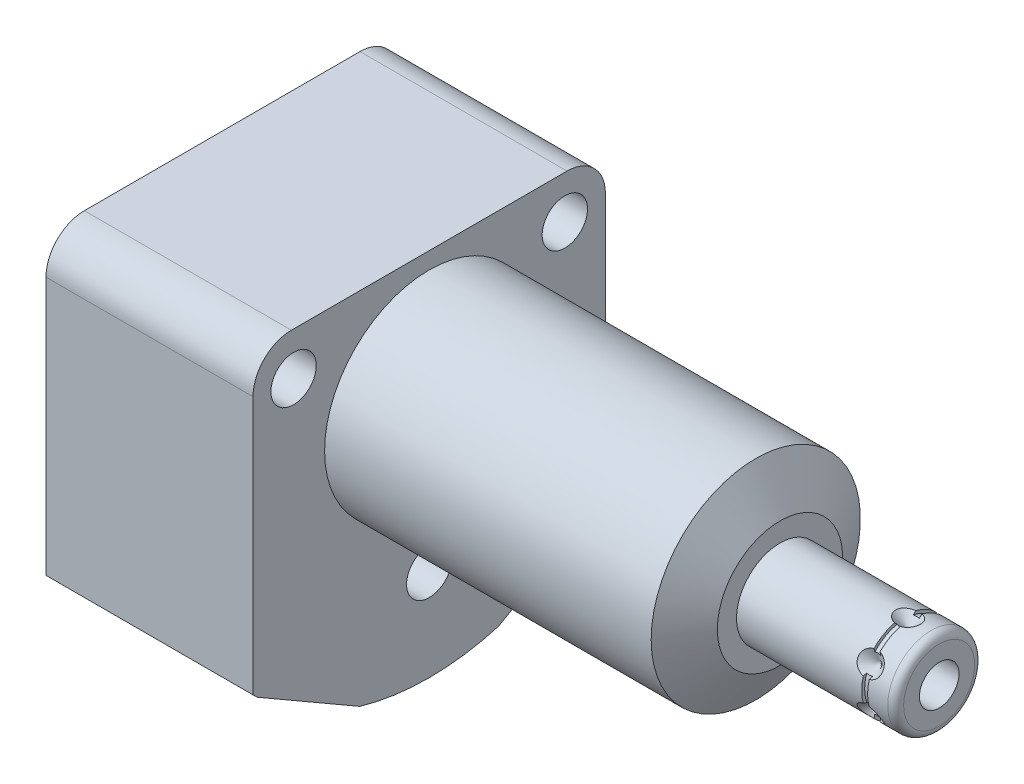
from build123d import *

# Parameters (mm, degrees)
EXTRUDE1_DEPTH           = 44.8056
EXTRUDE1_DEPTH_BACK      = 26.4414
CUT_EXTRUDE1_REACH       = 46.806
SKETCH2_R                = 13.3604
SKETCH11_W               = 0.762
SKETCH11_H               = 0.381
SKETCH15_R               = 2.7432
EXTRUDE3_DEPTH           = 2.9972
CUT_EXTRUDE2_DEPTH       = 2.54
CHAMFER1_SIZE            = 0.381
CHAMFER1_OF_MIRROR2_SIZE = 0.381
SKETCH21_R               = 0.889
FILLET1_R                = 4.9022
SKETCH22_W               = 2.8955
SKETCH22_H               = 26.4414
HOLE1_AT_2_COUNT         = 2
HOLE1_AT_2_PITCH         = 34.639910603
HOLE1_AT_3_COUNT         = 2
HOLE1_AT_3_PITCH         = 34.639910603
CIRPATTERN1_COUNT        = 6


with BuildPart() as part:
    # Sketch1 → Extrude1 (new body, two sides)
    with BuildSketch(Plane(origin=(0, 0, 0), x_dir=(0, 0, -1), z_dir=(1, 0, 0))) as extrude1_sk:
        with BuildLine():
            Line((-22.5044, 15.494), (-22.5044, -22.396751564))
            ThreePointArc((-22.5044, -22.396751564), (-22.237765115, -22.661515896), (-21.968015496, -22.923106141))
            Line((-21.968015496, -22.923106141), (-8.867984504, -30.486412561))
            ThreePointArc((-8.867984504, -30.486412561), (0, -31.75), (8.867984504, -30.486412561))
            Line((8.867984504, -30.486412561), (21.968015496, -22.923106141))
            ThreePointArc((21.968015496, -22.923106141), (22.237765115, -22.661515896), (22.5044, -22.396751564))
            Line((22.5044, -22.396751564), (22.5044, 15.494))
            Line((22.5044, 15.494), (-22.5044, 15.494))
        make_face()
    extrude(amount=EXTRUDE1_DEPTH)
    extrude(extrude1_sk.sketch, amount=-EXTRUDE1_DEPTH_BACK)

    # Sketch2 → Cut-Extrude1 (cut, up to next)
    with BuildSketch(Plane(origin=(0, 0, 0), x_dir=(0, 0, -1), z_dir=(1, 0, 0)), mode=Mode.PRIVATE) as cut_extrude1_sk1:
        with BuildLine():
            Line((22.5044, 15.494), (-22.5044, 15.494))
            Line((-22.5044, 15.494), (-22.5044, -22.396751564))
            ThreePointArc((-22.5044, -22.396751564), (-22.237765115, -22.661515896), (-21.968015496, -22.923106141))
            Line((-21.968015496, -22.923106141), (-8.867984504, -30.486412561))
            ThreePointArc((-8.867984504, -30.486412561), (0, -31.75), (8.867984504, -30.486412561))
            Line((8.867984504, -30.486412561), (21.968015496, -22.923106141))
            ThreePointArc((21.968015496, -22.923106141), (22.237765115, -22.661515896), (22.5044, -22.396751564))
            Line((22.5044, -22.396751564), (22.5044, 15.494))
        make_face()
        Circle(SKETCH2_R, mode=Mode.SUBTRACT)
    cut_extrude1_tool1 = extrude(cut_extrude1_sk1.sketch, amount=CUT_EXTRUDE1_REACH, mode=Mode.PRIVATE) & part.part
    add(cut_extrude1_tool1.solids().sort_by_distance((0, -3.451376, -21.851883))[0], mode=Mode.SUBTRACT)

    # Sketch3 → Cut-Revolve1 (revolve, cut)
    with BuildSketch(Plane.XY, mode=Mode.PRIVATE) as cut_revolve1_sk:
        Polygon((41.711348967, 13.3604), (44.8056, 8.001), (44.8056, 13.3604), align=None)
    revolve(cut_revolve1_sk.sketch.rotate(Axis((23.304450239, 0, 0), (1, 0, 0)), 90), axis=Axis((23.304450239, 0, 0), (1, 0, 0)), mode=Mode.SUBTRACT)  # turned: the seam where the file's is

    # S2D0002 → Cut-Revolve2 (revolve, cut)
    with BuildSketch(Plane(origin=(-24.9936, -18.1864, 10.49), x_dir=(0, 1, 0), z_dir=(0, 0, 1)), mode=Mode.PRIVATE) as cut_revolve2_sk:
        Polygon((3.2512, 0), (5.7023, 0), (5.7023, 1.4478), (0, 1.4478), (0, -11.9888), (1.2446, -11.9888), (1.2446, -2.9972), (3.2512, -2.9972), align=None)
    cut_revolve2 = revolve(cut_revolve2_sk.sketch.rotate(Axis((-1.435104963, -18.1864, 10.49), (-1, 0, 0)), 90), axis=Axis((-1.435104963, -18.1864, 10.49), (-1, 0, 0)), mode=Mode.SUBTRACT)  # turned: the seam where the file's is

    # Sketch6 → Cut-Revolve4 (revolve, cut)
    with BuildSketch(Plane(origin=(-12.9286, 0, 0), x_dir=(0, 0, -1), z_dir=(1, 0, 0)), mode=Mode.PRIVATE) as cut_revolve4_sk:
        Polygon((-19.580423825, -24.008288899), (-22.435709581, -22.359788899), (-22.562709581, -22.579759351), (-15.418, -26.704759351), (-10.0078, -17.334018072), (-13.835285875, -15.124218072), (-18.788285875, -23.703065722), (-19.516923825, -23.898303672), align=None)
    cut_revolve4 = revolve(cut_revolve4_sk.sketch.rotate(Axis((-12.9286, -11.344731937, 6.549884038), (0, 0.866025404, -0.5)), 180), axis=Axis((-12.9286, -11.344731937, 6.549884038), (0, 0.866025404, -0.5)), mode=Mode.SUBTRACT)  # turned: the seam where the file's is

    # Mirror1: Cut-Revolve2, Cut-Revolve4 across plane
    add(cut_revolve2.mirror(Plane.XY), mode=Mode.SUBTRACT)
    add(cut_revolve4.mirror(Plane.XY), mode=Mode.SUBTRACT)

    # Sketch7 → Revolve1 (revolve)
    with BuildSketch(Plane.XY, mode=Mode.PRIVATE) as revolve1_sk:
        with BuildLine():
            Line((44.8056, 0), (44.8056, 5.55625))
            Line((44.8056, 5.55625), (64.1226, 5.55625))
            ThreePointArc((64.1226, 5.55625), (64.84102049, 5.25867049), (65.1386, 4.54025))
            Line((65.1386, 4.54025), (65.1386, 0))
            Line((65.1386, 0), (44.8056, 0))
        make_face()
    revolve(revolve1_sk.sketch.rotate(Axis((4.993122661, 0, 0), (1, 0, 0)), 90), axis=Axis((4.993122661, 0, 0), (1, 0, 0)))  # turned: the seam where the file's is

    # S2D0001 → Cut-Revolve8 (revolve, cut)
    with BuildSketch(Plane.XY, mode=Mode.PRIVATE) as cut_revolve8_sk:
        Polygon((65.1386, -2.5273), (54.9786, -2.5273), (53.460044958, 0), (65.1386, 0), align=None)
    revolve(cut_revolve8_sk.sketch.rotate(Axis((-2.5273, 0, 0), (-1, 0, 0)), 90), axis=Axis((-2.5273, 0, 0), (-1, 0, 0)), mode=Mode.SUBTRACT)  # turned: the seam where the file's is

    # Sketch9 → Cut-Revolve9 (revolve, cut)
    with BuildSketch(Plane.XY, mode=Mode.PRIVATE) as cut_revolve9_sk:
        Polygon((61.1762, -5.55625), (59.5887, -5.55625), (61.1762, -3.96875), align=None)
    cut_revolve9 = revolve(cut_revolve9_sk.sketch.rotate(Axis((61.1762, -6.253416753, 0), (0, 1, 0)), 270), axis=Axis((61.1762, -6.253416753, 0), (0, 1, 0)), mode=Mode.SUBTRACT)  # turned: the seam where the file's is

    # Sketch11 → Cut-Revolve5 (revolve, cut)
    with BuildSketch(Plane(origin=(0, 0, 0), x_dir=(1, 0, 0), z_dir=(0, 1, 0))):
        with Locations((61.1762, -5.36575)):
            Rectangle(SKETCH11_W, SKETCH11_H)
    revolve(axis=Axis((0, 0, 0), (1, 0, 0)), mode=Mode.SUBTRACT)

    # Sketch15 → Extrude3 (add)
    with BuildSketch(Plane.ZY.offset(21.9964)):
        with Locations(Location((10.49, -18.1864, 0), (0, 0, 180))):  # turned: the seam where the file's is
            Circle(SKETCH15_R)
    extrude3 = extrude(amount=EXTRUDE3_DEPTH)

    # Sketch16 → Cut-Extrude2 (cut)
    with BuildSketch(Plane.ZY.offset(24.9936)):
        Polygon((11.92714029, -18.1864), (11.208570145, -16.9418), (9.771429855, -16.9418), (9.05285971, -18.1864), (9.771429855, -19.431), (11.208570145, -19.431), align=None)
    cut_extrude2 = extrude(amount=-CUT_EXTRUDE2_DEPTH, mode=Mode.SUBTRACT)

    # Chamfer1
    chamfer1_edges = [part.edges().sort_by_distance(p)[0] for p in [
        (-24.9936, -18.1864, 13.2332),
    ]]
    chamfer(chamfer1_edges, length=CHAMFER1_SIZE)

    # Mirror2: Extrude3, Cut-Extrude2 across plane
    add(extrude3.mirror(Plane.XY))
    add(cut_extrude2.mirror(Plane.XY), mode=Mode.SUBTRACT)

    # Chamfer1 of Mirror2
    chamfer1_of_mirror2_edges = [part.edges().sort_by_distance(p)[0] for p in [
        (-24.9936, -18.1864, -13.2332),
    ]]
    chamfer(chamfer1_of_mirror2_edges, length=CHAMFER1_OF_MIRROR2_SIZE)

    # Fillet1
    fillet1_edges = [part.edges().sort_by_distance(p)[0] for p in [
        (-13.2207, 15.494, -22.5044),
        (-13.2207, 15.494, 22.5044),
    ]]
    fillet(fillet1_edges, radius=FILLET1_R)

    # Sketch22 → Hole1 (revolve, cut)
    with BuildSketch(Plane(origin=(0, -19.9898, 0), x_dir=(0, 0, -1), z_dir=(0, 1, 0))):
        with Locations((1.44775, 13.2207)):
            Rectangle(SKETCH22_W, SKETCH22_H)
    hole1 = revolve(axis=Axis((-110, -19.9898, 0), (1, 0, 0)), mode=Mode.SUBTRACT)

    # Hole1 at 2: Hole1 ×2
    with Locations(*[Vector(0, 0.865977985, 0.500082122) * (i * HOLE1_AT_2_PITCH) for i in range(1, HOLE1_AT_2_COUNT)]):
        add(hole1, mode=Mode.SUBTRACT)

    # Hole1 at 3: Hole1 ×2
    with Locations(*[Vector(0, 0.865977985, -0.500082122) * (i * HOLE1_AT_3_PITCH) for i in range(1, HOLE1_AT_3_COUNT)]):
        add(hole1, mode=Mode.SUBTRACT)

    # CirPattern1: Cut-Revolve9 ×6 about axis
    cirpattern1_axis = Axis((0, 0, 0), (1, 0, 0))
    for i in range(1, CIRPATTERN1_COUNT):
        add(cut_revolve9.rotate(cirpattern1_axis, i * 360 / CIRPATTERN1_COUNT), mode=Mode.SUBTRACT)


with BuildPart() as body_2:
    # Sketch21 → Revolve4 (revolve)
    with BuildSketch(Plane.XY.offset(10.49), mode=Mode.PRIVATE) as revolve4_sk:
        with Locations((-25.8572, -13.3731)):
            Circle(SKETCH21_R)
    revolve(revolve4_sk.sketch.rotate(Axis((-35.974373203, -18.1864, 10.49), (1, 0, 0)), 270), axis=Axis((-35.974373203, -18.1864, 10.49), (1, 0, 0)))  # turned: the seam where the file's is


with BuildPart() as body_3:
    # Mirror3: mirrored copy
    add(body_2.part.mirror(Plane.XY))


solid = Compound([part.part, body_2.part, body_3.part])
